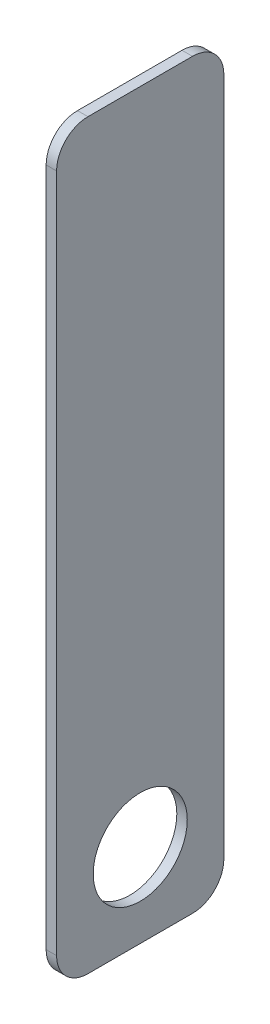
from build123d import *

# Parameters (mm, degrees)
SKETCH1_W           = 50.8
SKETCH1_H           = 225.425
SKETCH1_R           = 14.2875
BOSS_EXTRUDE1_DEPTH = 3.175
FILLET1_R           = 9.525


with BuildPart() as part:
    # Sketch1 → Boss-Extrude1 (new body)
    with BuildSketch(Plane(origin=(0, 0, 0), x_dir=(0, 0, -1), z_dir=(1, 0, 0))):
        Rectangle(SKETCH1_W, SKETCH1_H)
        with Locations((0, -87.3125)):
            Circle(SKETCH1_R, mode=Mode.SUBTRACT)
    extrude(amount=BOSS_EXTRUDE1_DEPTH)

    # Fillet1
    fillet1_edges = [part.edges().sort_by_distance(p)[0] for p in [
        (1.5875, 112.7125, 25.4),
        (1.5875, 112.7125, -25.4),
        (1.5875, -112.7125, -25.4),
        (1.5875, -112.7125, 25.4),
    ]]
    fillet(fillet1_edges, radius=FILLET1_R)


solid = part.part
